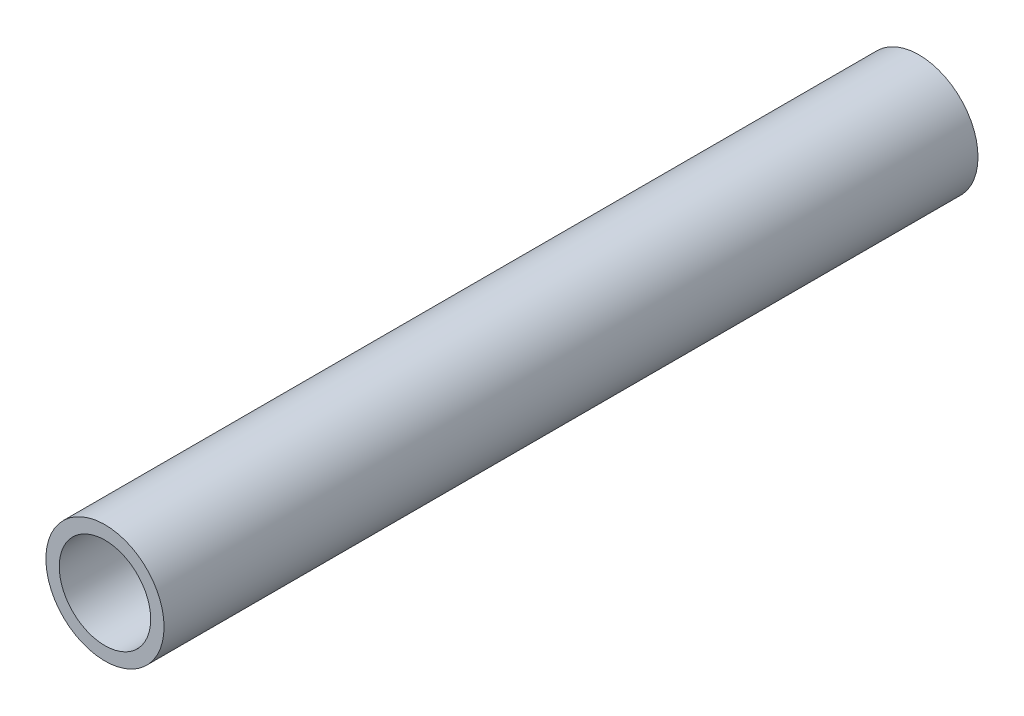
from build123d import *

# Parameters (mm, degrees)
SKETCH1_R           = 4.425
SKETCH1_R_2         = 3.425
BOSS_EXTRUDE1_DEPTH = 60.96


with BuildPart() as part:
    # Sketch1 → Boss-Extrude1 (new body)
    with BuildSketch(Plane.XY):
        Circle(SKETCH1_R)
        Circle(SKETCH1_R_2, mode=Mode.SUBTRACT)
    extrude(amount=BOSS_EXTRUDE1_DEPTH)


solid = part.part
